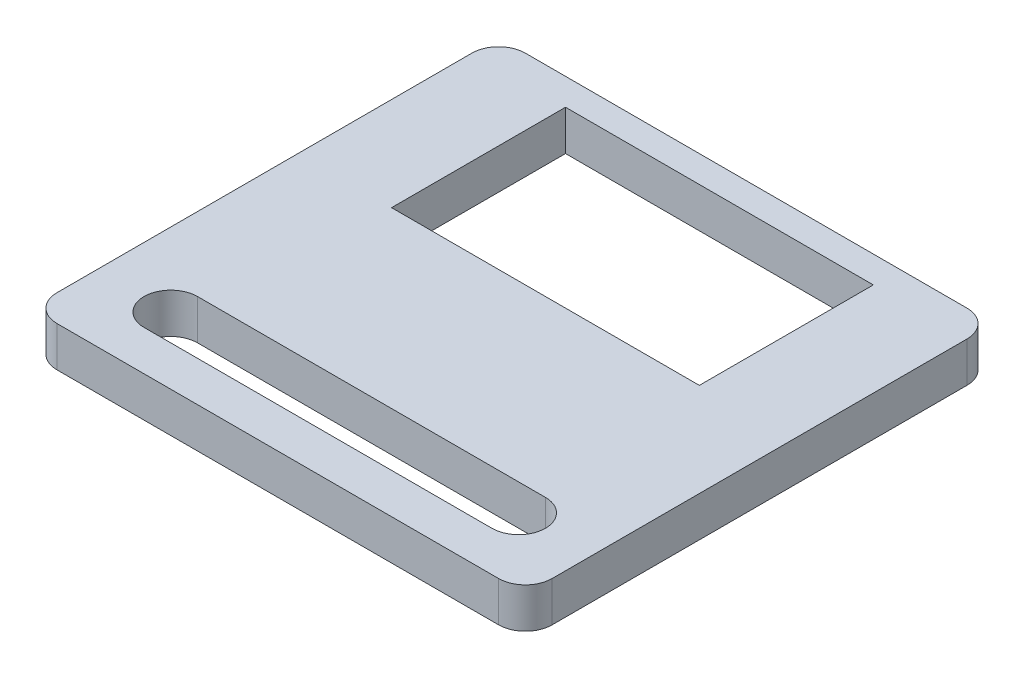
from build123d import *

# Parameters (mm, degrees)
SKETCH1_W           = 37
SKETCH1_H           = 35
SKETCH1_W_2         = 23
SKETCH1_H_2         = 13
BOSS_EXTRUDE1_DEPTH = 3
FILLET1_R           = 2


with BuildPart() as part:
    # Sketch1 → Boss-Extrude1 (new body)
    with BuildSketch(Plane(origin=(0, 0, 0), x_dir=(1, 0, 0), z_dir=(0, 1, 0))):
        Rectangle(SKETCH1_W, SKETCH1_H)
        with Locations((0, 9)):
            Rectangle(SKETCH1_W_2, SKETCH1_H_2, mode=Mode.SUBTRACT)
        with BuildLine():
            Line((-13, -10.5), (13, -10.5))
            ThreePointArc((13, -10.5), (15, -12.5), (13, -14.5))
            Line((13, -14.5), (-13, -14.5))
            ThreePointArc((-13, -14.5), (-15, -12.5), (-13, -10.5))
        make_face(mode=Mode.SUBTRACT)
    extrude(amount=BOSS_EXTRUDE1_DEPTH)

    # Fillet1
    fillet1_edges = [part.edges().sort_by_distance(p)[0] for p in [
        (18.5, 1.5, 17.5),
        (-18.5, 1.5, 17.5),
        (-18.5, 1.5, -17.5),
        (18.5, 1.5, -17.5),
    ]]
    fillet(fillet1_edges, radius=FILLET1_R)


solid = part.part
